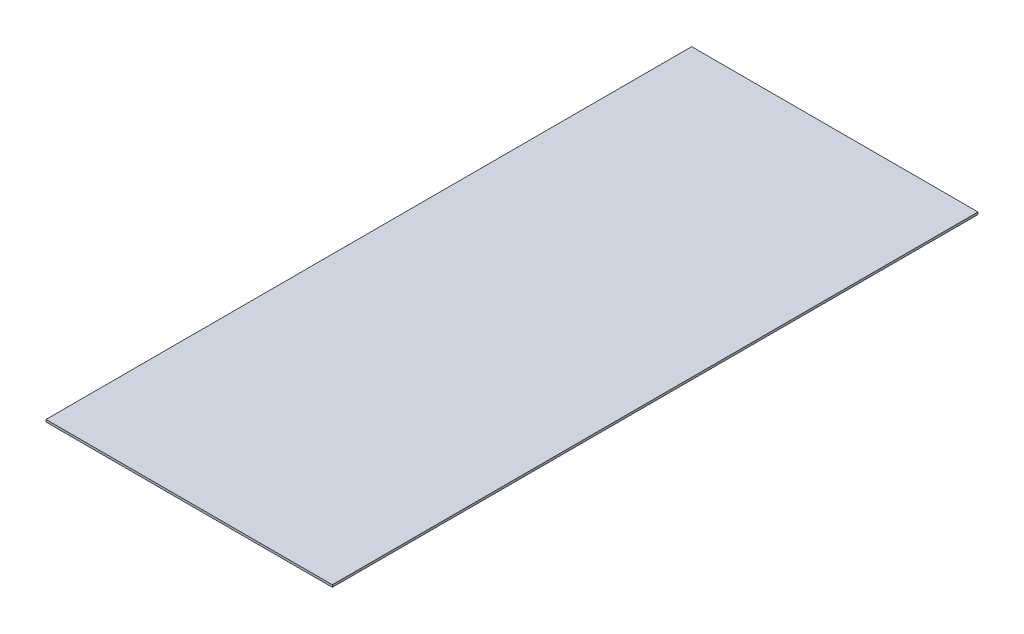
from build123d import *

# Parameters (mm, degrees)
SKETCH1_W           = 323.85
SKETCH1_H           = 730.25
BOSS_EXTRUDE1_DEPTH = 1.27


with BuildPart() as part:
    # Sketch1 → Boss-Extrude1 (new body, symmetric)
    with BuildSketch(Plane(origin=(0, 0, 0), x_dir=(1, 0, 0), z_dir=(0, 1, 0))):
        Rectangle(SKETCH1_W, SKETCH1_H)
    extrude(amount=BOSS_EXTRUDE1_DEPTH, both=True)


solid = part.part
